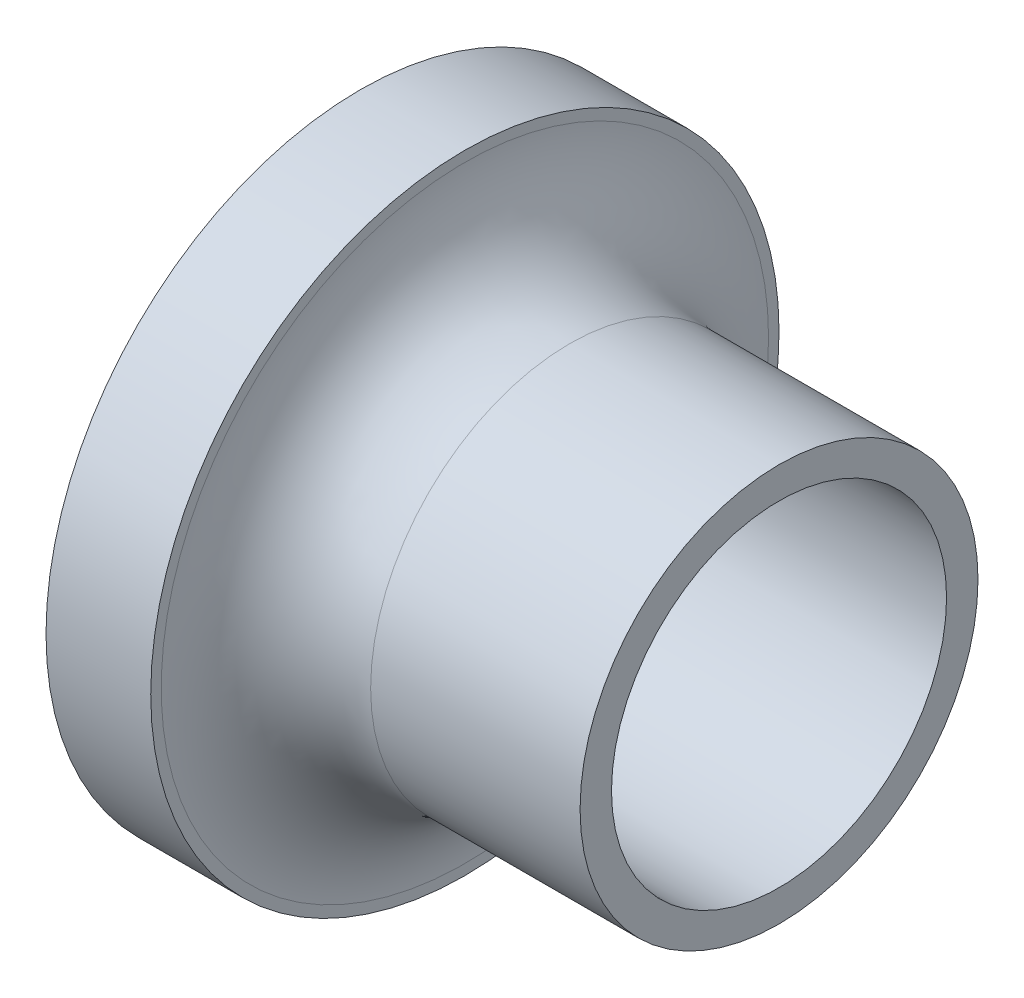
from build123d import *

# Parameters (mm, degrees)
SCHIZZO1_R                   = 9.5
SCHIZZO1_R_2                 = 8
ESTRUSIONE_ESTRUSIONE1_DEPTH = 20
SCHIZZO2_R                   = 15
ESTRUSIONE_ESTRUSIONE2_DEPTH = 5
RACCORDO1_R                  = 5


with BuildPart() as part:
    # Schizzo1 → Estrusione-Estrusione1 (new body)
    with BuildSketch(Plane(origin=(0, 0, 0), x_dir=(0, 0, -1), z_dir=(1, 0, 0))):
        Circle(SCHIZZO1_R)
        Circle(SCHIZZO1_R_2, mode=Mode.SUBTRACT)
    extrude(amount=ESTRUSIONE_ESTRUSIONE1_DEPTH)

    # Schizzo2 → Estrusione-Estrusione2 (add)
    with BuildSketch(Plane(origin=(0, 0, 0), x_dir=(0, 0, -1), z_dir=(1, 0, 0))):
        Circle(SCHIZZO2_R)
    extrude(amount=ESTRUSIONE_ESTRUSIONE2_DEPTH)

    # Raccordo1
    raccordo1_edges = [part.edges().sort_by_distance(p)[0] for p in [
        (5, 0, 9.5),
    ]]
    fillet(raccordo1_edges, radius=RACCORDO1_R)


solid = part.part
